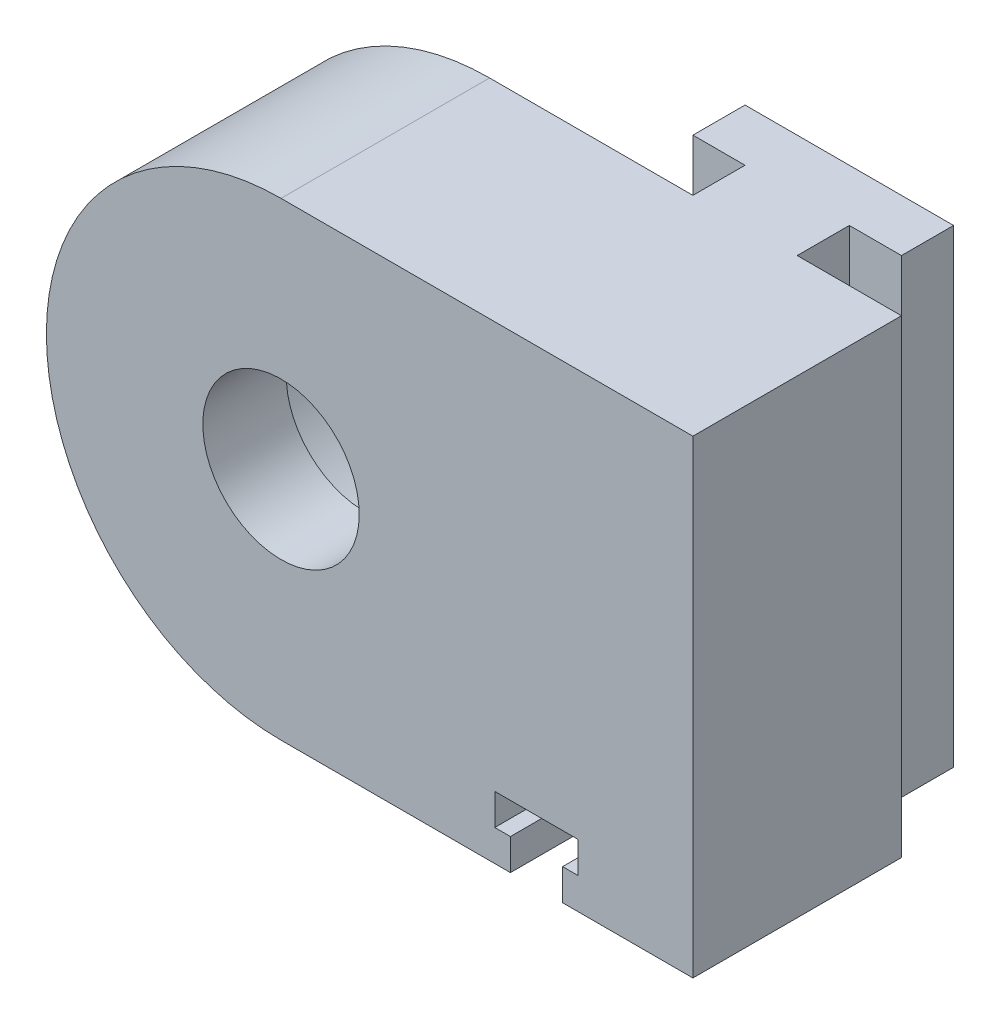
from build123d import *

# Parameters (mm, degrees)
ESQUISSE1_R                  = 7.5
BOSS_EXTRU_1_DEPTH           = 10
ENL_V_MAT_EXTRU_1_DEPTH      = 2
ENL_V_MAT_EXTRU_1_DEPTH_BACK = 10
ESQUISSE1_5_R                = 14
BOSS_EXTRU_2_DEPTH           = 45
ENL_V_MAT_EXTRU_2_DEPTH      = 658.768842069
ENL_V_MAT_EXTRU_2_DEPTH_BACK = 658.768842069


with BuildPart() as part:
    # Esquisse1 → Boss.-Extru.1 (new, symmetric)
    with BuildSketch(Plane.XY):
        with BuildLine():
            Line((-634.508066615, 20.5), (-595.008671928, 20.5))
            Line((-595.008671928, 20.5), (-595.008671928, -24.5))
            Line((-595.008671928, -24.5), (-634.508066615, -24.5))
            ThreePointArc((-634.508066615, -24.5), (-657.008066615, -2), (-634.508066615, 20.5))
        make_face()
        with Locations((-634.508066615, -2)):
            Circle(ESQUISSE1_R, mode=Mode.SUBTRACT)
    extrude(amount=BOSS_EXTRU_1_DEPTH, both=True)

    # Esquisse1_5 → Enl_v. mat.-Extru.1 (cut, two sides: drawn at the far end of the back side and taken through both)
    with BuildSketch(Plane.XY.offset(-ENL_V_MAT_EXTRU_1_DEPTH_BACK)):
        with Locations((-634.508066615, -2)):
            Circle(ESQUISSE1_5_R)
    extrude(amount=ENL_V_MAT_EXTRU_1_DEPTH + ENL_V_MAT_EXTRU_1_DEPTH_BACK, mode=Mode.SUBTRACT)

    # Esquisse2 → Boss.-Extru.2 (add)
    with BuildSketch(Plane(origin=(0, 20.5, 0), x_dir=(1, 0, 0), z_dir=(0, 1, 0))):
        Polygon((-605.008671928, 10), (-605.008671928, 15), (-600.008671928, 15), (-600.008671928, 20), (-620.008671928, 20), (-620.008671928, 15), (-615.008671928, 15), (-615.008671928, 10), align=None)
    extrude(amount=-BOSS_EXTRU_2_DEPTH)

    # Esquisse1_7 → Enl_v. mat.-Extru.2 (cut, two sides: drawn at the far end of the back side and taken through both)
    with BuildSketch(Plane.XY.offset(-ENL_V_MAT_EXTRU_2_DEPTH_BACK)):
        Polygon((-612.508671928, -21.5), (-612.508671928, -24.5), (-607.508671928, -24.5), (-607.508671928, -21.5), (-606.008671928, -21.5), (-606.008671928, -18.5), (-614.008671928, -18.5), (-614.008671928, -21.5), align=None)
    extrude(amount=ENL_V_MAT_EXTRU_2_DEPTH + ENL_V_MAT_EXTRU_2_DEPTH_BACK, mode=Mode.SUBTRACT)


solid = part.part
